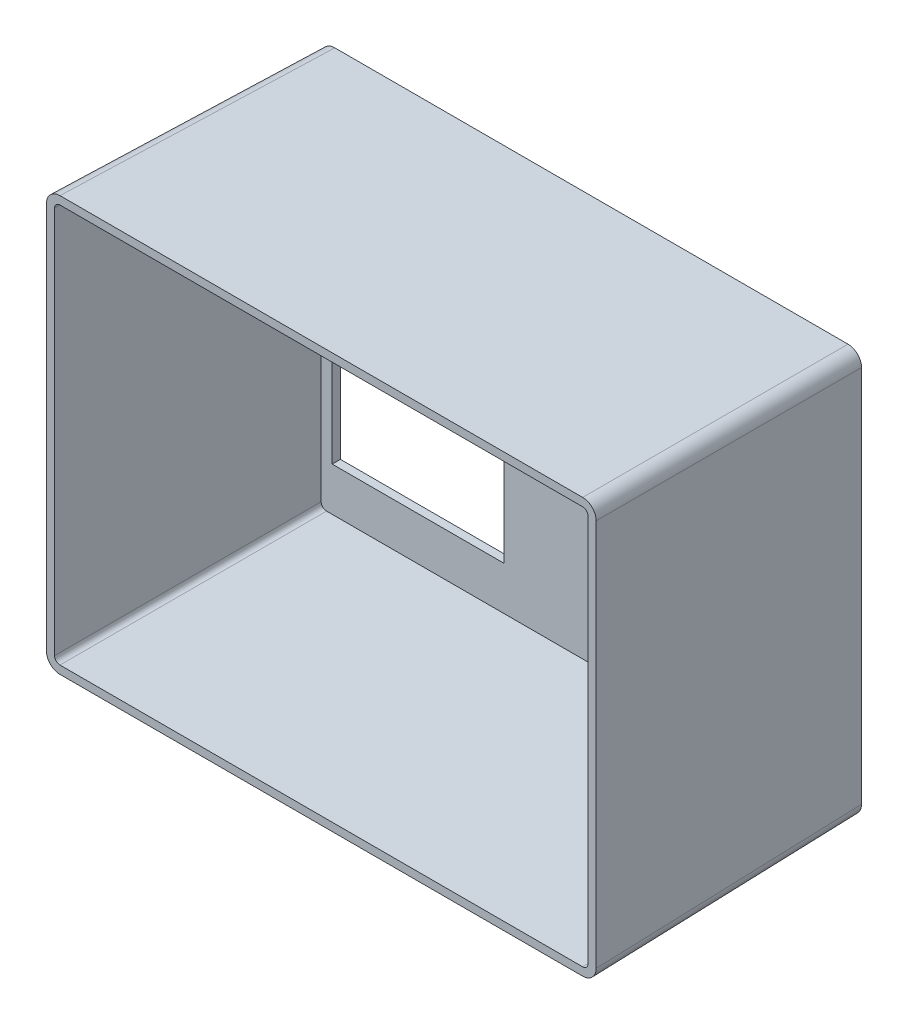
from build123d import *

# Parameters (mm, degrees)
SKETCH3_W           = 200
SKETCH3_H           = 150
BOSS_EXTRUDE1_DEPTH = 100
BOSS_EXTRUDE1_TAPER = -1
FILLET1_R           = 5
SHELL1_T            = -3
SKETCH10_W          = 20
SKETCH10_H          = 25.4
SKETCH10_W_2        = 50
SKETCH10_H_2        = 20
CUT_EXTRUDE6_DEPTH  = 59.614
CUT_EXTRUDE6_TAPER  = -1
SKETCH12_W          = 63.5
SKETCH12_H          = 38.1
CUT_EXTRUDE7_DEPTH  = 100
CUT_EXTRUDE7_TAPER  = -1


with BuildPart() as part:
    # Sketch3 → Boss-Extrude1 (new body)
    with BuildSketch(Plane.XY):
        with Locations((-28.926930074, 63.110328622)):
            Rectangle(SKETCH3_W, SKETCH3_H)
    extrude(amount=BOSS_EXTRUDE1_DEPTH, taper=BOSS_EXTRUDE1_TAPER)

    # Fillet1
    fillet1_edges = [part.edges().sort_by_distance(p)[0] for p in [
        (71.945823172, -12.762424624, 50),
        (-129.799683321, -12.762424624, 50),
        (-129.799683321, 138.983081869, 50),
        (71.945823172, 138.983081869, 50),
    ]]
    fillet(fillet1_edges, radius=FILLET1_R)

    # Shell1
    shell1_openings = [part.faces().sort_by_distance(p)[0] for p in [
        (-28.926930074, 63.110328622, 100),
    ]]
    offset(amount=SHELL1_T, openings=shell1_openings, kind=Kind.INTERSECTION)

    # Sketch10 → Cut-Extrude6 (cut)
    with BuildSketch(Plane(origin=(0, 0, 0), x_dir=(-1, 0, 0), z_dir=(0, 0, -1))):
        with Locations((-41.331432063, 119.367467356)):
            Rectangle(SKETCH10_W, SKETCH10_H)
        with Locations((-38.825178327, 7.672208688)):
            Rectangle(SKETCH10_W_2, SKETCH10_H_2)
    extrude(amount=-CUT_EXTRUDE6_DEPTH, taper=CUT_EXTRUDE6_TAPER, mode=Mode.SUBTRACT)

    # Sketch12 → Cut-Extrude7 (cut)
    with BuildSketch(Plane(origin=(0, 0, 0), x_dir=(-1, 0, 0), z_dir=(0, 0, -1))):
        with Locations((90.091836521, 26.275420471)):
            Rectangle(SKETCH12_W, SKETCH12_H)
    extrude(amount=-CUT_EXTRUDE7_DEPTH, taper=CUT_EXTRUDE7_TAPER, mode=Mode.SUBTRACT)


solid = part.part
